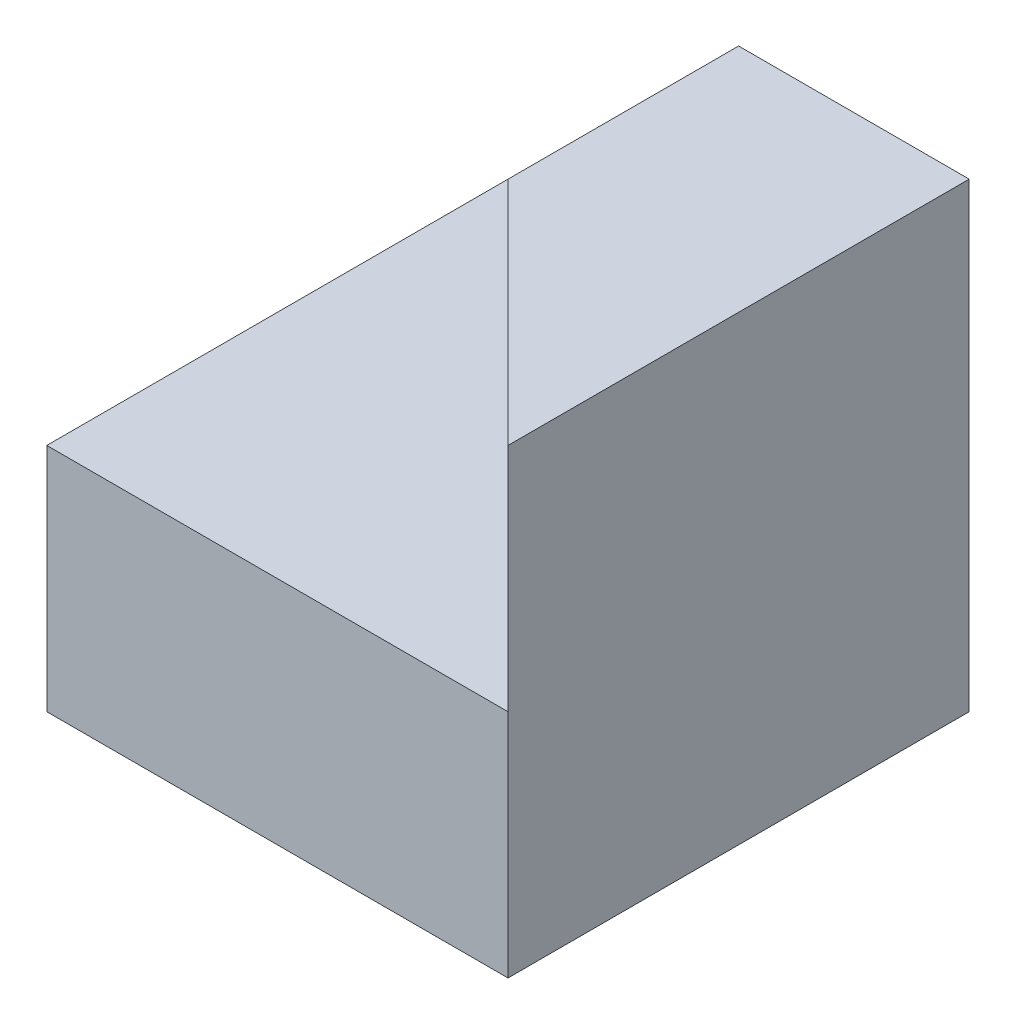
from build123d import *

# Parameters (mm, degrees)
SKETCH1_W           = 40
SKETCH1_H           = 20
BOSS_EXTRUDE1_DEPTH = 40
SKETCH2_W           = 20
SKETCH2_H           = 20
BOSS_EXTRUDE2_DEPTH = 40
CUT_EXTRUDE2_DEPTH  = 20
CUT_EXTRUDE3_DEPTH  = 20
BOSS_EXTRUDE3_DEPTH = 20
BOSS_EXTRUDE4_DEPTH = 20
CUT_EXTRUDE4_DEPTH  = 20


with BuildPart() as part:
    # Sketch1 → Boss-Extrude1 (new body)
    with BuildSketch(Plane.XY):
        with Locations((20, 10)):
            Rectangle(SKETCH1_W, SKETCH1_H)
    extrude(amount=BOSS_EXTRUDE1_DEPTH)

    # Sketch2 → Boss-Extrude2 (add)
    with BuildSketch(Plane.XY.offset(40)):
        with Locations((30, 30)):
            Rectangle(SKETCH2_W, SKETCH2_H)
    extrude(amount=-BOSS_EXTRUDE2_DEPTH)

    # Sketch3 → Cut-Extrude2 (cut)
    with BuildSketch(Plane(origin=(0, 40, 0), x_dir=(1, 0, 0), z_dir=(0, 1, 0))):
        Polygon((40, -40), (40, -20), (20, -40), align=None)
    extrude(amount=-CUT_EXTRUDE2_DEPTH, mode=Mode.SUBTRACT)

    # Sketch4 → Cut-Extrude3 (cut)
    with BuildSketch(Plane(origin=(0, 40, 0), x_dir=(1, 0, 0), z_dir=(0, 1, 0))):
        Polygon((40, 0), (20, -20), (20, 0), align=None)
    extrude(amount=-CUT_EXTRUDE3_DEPTH, mode=Mode.SUBTRACT)

    # Sketch5 → Boss-Extrude3 (add)
    with BuildSketch(Plane(origin=(0, 20, 0), x_dir=(1, 0, 0), z_dir=(0, 1, 0))):
        Polygon((20, 0), (20, -20), (40, 0), align=None)
    extrude(amount=BOSS_EXTRUDE3_DEPTH)

    # Sketch6 → Boss-Extrude4 (add)
    with BuildSketch(Plane(origin=(0, 20, 0), x_dir=(1, 0, 0), z_dir=(0, 1, 0))):
        Polygon((20, -40), (40, -40), (40, -20), align=None)
    extrude(amount=BOSS_EXTRUDE4_DEPTH)

    # Sketch7 → Cut-Extrude4 (cut)
    with BuildSketch(Plane(origin=(0, 40, 0), x_dir=(1, 0, 0), z_dir=(0, 1, 0))):
        Polygon((20, -20), (20, -40), (30, -30), align=None)
        Polygon((30, -30), (20, -40), (40, -40), align=None)
    extrude(amount=-CUT_EXTRUDE4_DEPTH, mode=Mode.SUBTRACT)


solid = part.part
